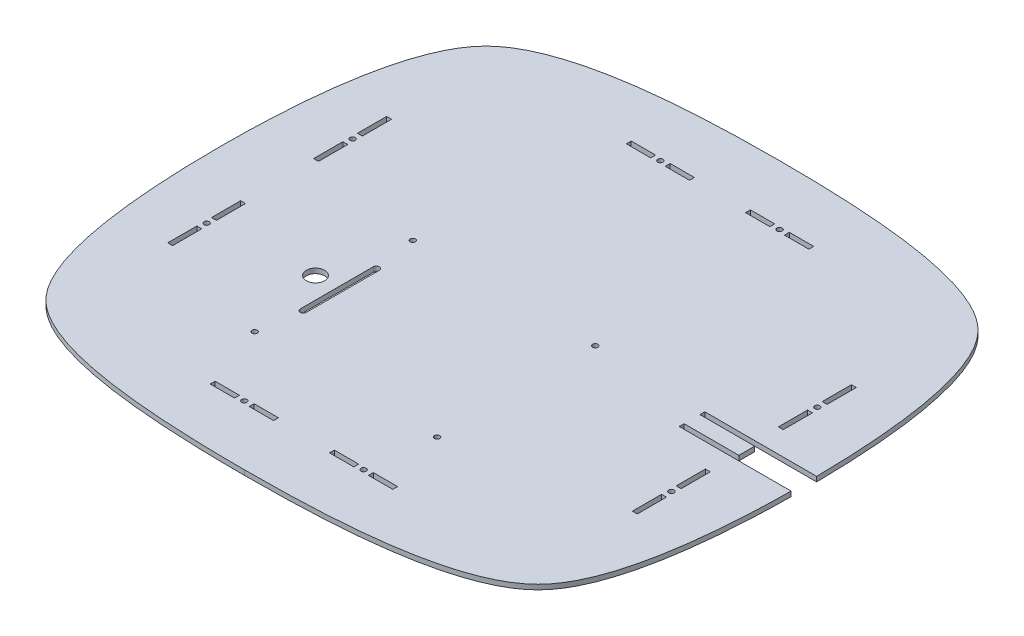
from build123d import *

# Parameters (mm, degrees)
BOSS_EXTRUDE1_DEPTH      = 4
SKETCH2_W                = 4
SKETCH2_H                = 24
SKETCH2_W_2              = 20
SKETCH2_H_2              = 4
CUT_EXTRUDE1_DEPTH       = 6
M4_CLEARANCE_HOLE1_D     = 4.3
M4_CLEARANCE_HOLE1_DEPTH = 6
M4_CLEARANCE_HOLE1_TIP   = 1.291850331
M4_CLEARANCE_HOLE2_D     = 4.3
M4_CLEARANCE_HOLE2_DEPTH = 6
M4_CLEARANCE_HOLE2_TIP   = 1.291850331
SKETCH7_R                = 7.5
CUT_EXTRUDE2_DEPTH       = 10


with BuildPart() as part:
    # Sketch1 → Boss-Extrude1 (new body)
    with BuildSketch(Plane(origin=(0, 0, 0), x_dir=(1, 0, 0), z_dir=(0, 1, 0))):
        with BuildLine():
            add(Edge.make_bspline(
                [(0, 220), (-73.455033332, 220), (-164.206703598, 213.723358009), (-232.08273123, 156.77614821), (-240, 64.870512103), (-240, 0)],
                knots=[0, 0, 0, 0, 0.467314197, 0.567314197, 1, 1, 1, 1], degree=3))
            add(Edge.make_bspline(
                [(0, -220), (-73.455033332, -220), (-164.206703598, -213.723358009), (-232.08273123, -156.77614821), (-240, -64.870512103), (-240, 0)],
                knots=[0, 0, 0, 0, 0.467314197, 0.567314197, 1, 1, 1, 1], degree=3))
            add(Edge.make_bspline(
                [(0, -220), (73.455033332, -220), (164.206703598, -213.723358009), (232.08273123, -156.77614821), (240, -64.870512103), (240, 0)],
                knots=[0, 0, 0, 0, 0.467314197, 0.567314197, 1, 1, 1, 1], degree=3))
            add(Edge.make_bspline(
                [(0, 220), (73.455033332, 220), (164.206703598, 213.723358009), (232.08273123, 156.77614821), (240, 64.870512103), (240, 0)],
                knots=[0, 0, 0, 0, 0.467314197, 0.567314197, 1, 1, 1, 1], degree=3))
        make_face()
    extrude(amount=BOSS_EXTRUDE1_DEPTH)

    # Sketch2 → Cut-Extrude1 (cut)
    with BuildSketch(Plane(origin=(0, 4, 0), x_dir=(1, 0, 0), z_dir=(0, 1, 0))):
        Polygon((148, 10.5), (240, 10.5), (240, 6.5), (240, -6.5), (240, -10.5), (148, -10.5), (148, -6.5), (193, -6.5), (193, 6.5), (148, 6.5), align=None)
        with Locations((-191, 78)):
            Rectangle(SKETCH2_W, SKETCH2_H)
        with Locations((-191, 42)):
            Rectangle(SKETCH2_W, SKETCH2_H)
        with Locations((-191, -42)):
            Rectangle(SKETCH2_W, SKETCH2_H)
        with Locations((-191, -78)):
            Rectangle(SKETCH2_W, SKETCH2_H)
        with Locations((65, 171)):
            Rectangle(SKETCH2_W_2, SKETCH2_H_2)
        with Locations((-65, -171)):
            Rectangle(SKETCH2_W_2, SKETCH2_H_2)
        with Locations((-33, -171)):
            Rectangle(SKETCH2_W_2, SKETCH2_H_2)
        with Locations((33, -171)):
            Rectangle(SKETCH2_W_2, SKETCH2_H_2)
        with Locations((65, -171)):
            Rectangle(SKETCH2_W_2, SKETCH2_H_2)
        with Locations((33, 171)):
            Rectangle(SKETCH2_W_2, SKETCH2_H_2)
        with Locations((-33, 171)):
            Rectangle(SKETCH2_W_2, SKETCH2_H_2)
        with Locations((-65, 171)):
            Rectangle(SKETCH2_W_2, SKETCH2_H_2)
        with Locations((191, -78)):
            Rectangle(SKETCH2_W, SKETCH2_H)
        with Locations((191, -42)):
            Rectangle(SKETCH2_W, SKETCH2_H)
        with Locations((191, 42)):
            Rectangle(SKETCH2_W, SKETCH2_H)
        with Locations((191, 78)):
            Rectangle(SKETCH2_W, SKETCH2_H)
    extrude(amount=-CUT_EXTRUDE1_DEPTH, mode=Mode.SUBTRACT)

    # M4 Clearance Hole1
    with Locations(Plane(origin=(0, 4, 0), x_dir=(-1, 0, 0), z_dir=(0, 1, 0))):
        with Locations((49, -171), (-49, -171), (-191, -60), (-191, 60), (-49, 171), (49, 171), (191, 60), (191, -60)):
            Hole(M4_CLEARANCE_HOLE1_D / 2, depth=M4_CLEARANCE_HOLE1_DEPTH)
            with Locations((0, 0, -(M4_CLEARANCE_HOLE1_DEPTH + M4_CLEARANCE_HOLE1_TIP / 2))):  # 118° drill point
                Cone(0, M4_CLEARANCE_HOLE1_D / 2, M4_CLEARANCE_HOLE1_TIP, mode=Mode.SUBTRACT)

    # M4 Clearance Hole2
    with Locations(Plane(origin=(0, 4, 0), x_dir=(-1, 0, 0), z_dir=(0, 1, 0))):
        with Locations((94, -12.5), (-56, -12.5), (-56, 117.5), (94, 117.5)):
            Hole(M4_CLEARANCE_HOLE2_D / 2, depth=M4_CLEARANCE_HOLE2_DEPTH)
            with Locations((0, 0, -(M4_CLEARANCE_HOLE2_DEPTH + M4_CLEARANCE_HOLE2_TIP / 2))):  # 118° drill point
                Cone(0, M4_CLEARANCE_HOLE2_D / 2, M4_CLEARANCE_HOLE2_TIP, mode=Mode.SUBTRACT)

    # Sketch7 → Cut-Extrude2 (cut)
    with BuildSketch(Plane(origin=(0, 4, 0), x_dir=(1, 0, 0), z_dir=(0, 1, 0))):
        with Locations((-109, -52.5)):
            Circle(SKETCH7_R)
        with BuildLine():
            Line((-86.5, -22.5), (-86.5, -82.5))
            ThreePointArc((-86.5, -82.5), (-89, -85), (-91.5, -82.5))
            Line((-91.5, -82.5), (-91.5, -22.5))
            ThreePointArc((-91.5, -22.5), (-89, -20), (-86.5, -22.5))
        make_face()
    extrude(amount=-CUT_EXTRUDE2_DEPTH, mode=Mode.SUBTRACT)


solid = part.part
